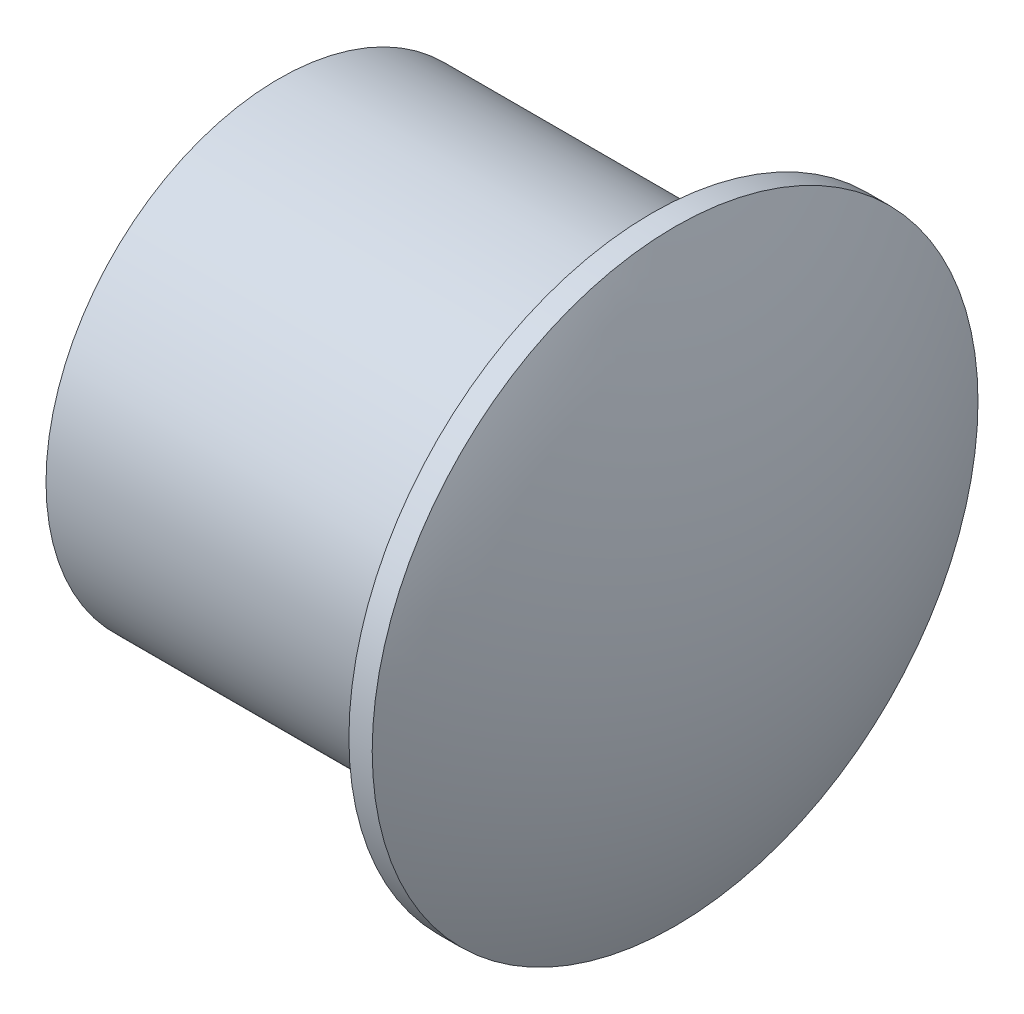
from build123d import *


with BuildPart() as part:
    # Sketch1 → Revolve1 (revolve)
    with BuildSketch(Plane.XY):
        with BuildLine():
            Line((0, 0), (0, 10))
            Line((0, 10), (16, 10))
            Line((16, 10), (16, 13))
            Line((16, 13), (17, 13))
            ThreePointArc((17, 13), (19.240272139, 6.670832032), (20, 0))
            Line((20, 0), (0, 0))
        make_face()
    revolve(axis=Axis((0, 0, 0), (1, 0, 0)))


solid = part.part
